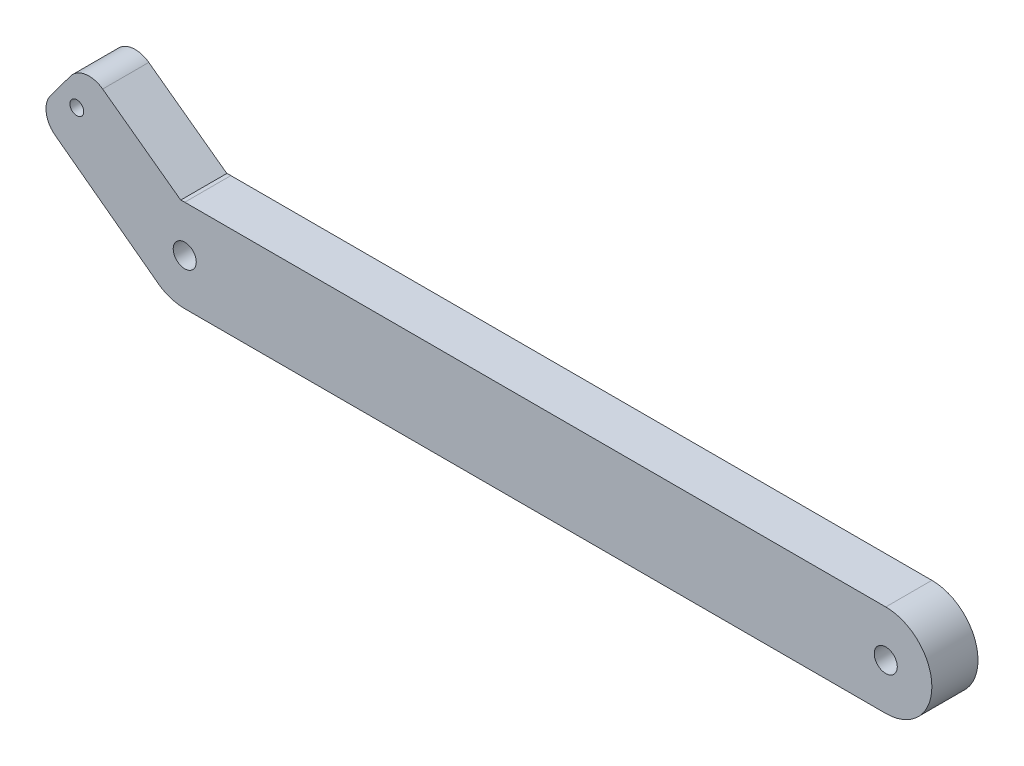
from build123d import *

# Parameters (mm, degrees)
ESQUISSE1_R        = 2.5
ESQUISSE1_R_2      = 1.5
BOSS_EXTRU_1_DEPTH = 10


with BuildPart() as part:
    # Esquisse1 → Boss.-Extru.1 (new body)
    with BuildSketch(Plane.XY):
        with BuildLine():
            Line((-5.305683683, 1.523578547), (-28.075920727, 18.488824386))
            ThreePointArc((-28.075920727, 18.488824386), (-30.036088987, 21.775525063), (-29.098088919, 25.485621667))
            Line((-29.098088919, 25.485621667), (-24.762545303, 31.304656462))
            ThreePointArc((-24.762545303, 31.304656462), (-21.496491478, 33.261764377), (-17.799326826, 32.351625643))
            Line((-17.799326826, 32.351625643), (-0.876599726, 19.961504551))
            ThreePointArc((-0.876599726, 19.961504551), (-0.438722287, 19.990371502), (0, 20))
            Line((0, 20), (152, 20))
            ThreePointArc((152, 20), (162, 10), (152, 0))
            Line((152, 0), (0, 0))
            ThreePointArc((0, 0), (-2.760053031, 0.388438875), (-5.305683683, 1.523578547))
        make_face()
        with Locations((0, 10)):
            Circle(ESQUISSE1_R, mode=Mode.SUBTRACT)
        with Locations((152, 10)):
            Circle(ESQUISSE1_R, mode=Mode.SUBTRACT)
        with Locations((-23.409755192, 26.035431675)):
            Circle(ESQUISSE1_R_2, mode=Mode.SUBTRACT)
    extrude(amount=BOSS_EXTRU_1_DEPTH)


solid = part.part
